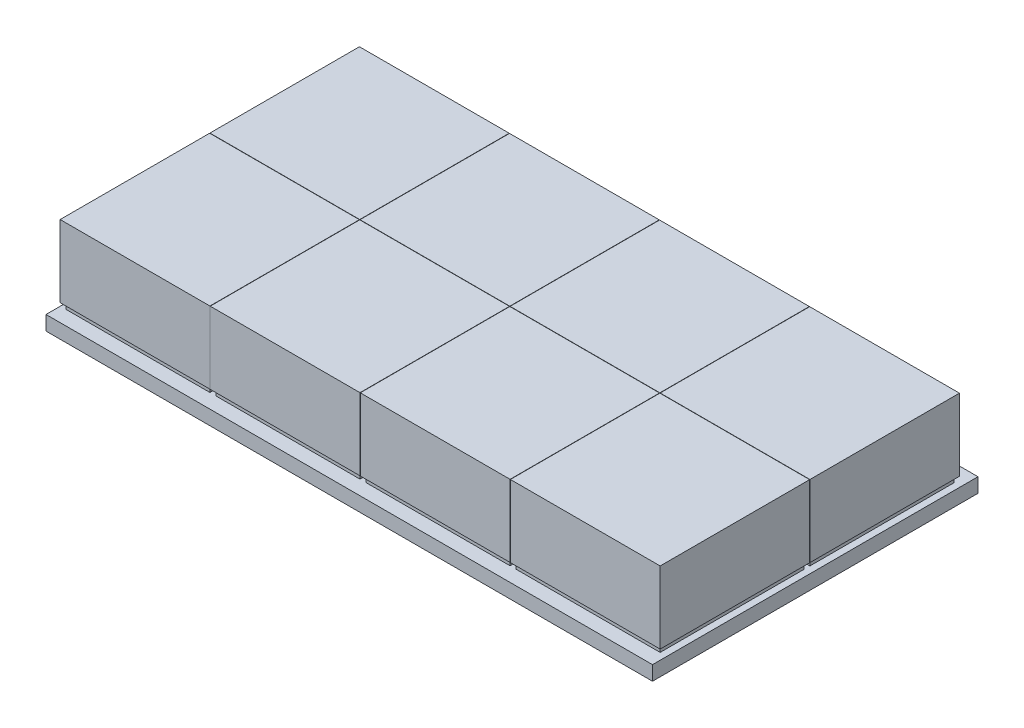
from build123d import *

# Parameters (mm, degrees)
SKETCH1_W                 = 500
SKETCH1_H                 = 113
BOSS_EXTRUDE1_DEPTH       = 5
SKETCH2_W                 = 50
SKETCH2_H                 = 50
BOSS_EXTRUDE3_DEPTH       = 2
LPATTERN1_COUNT           = 2
LPATTERN1_PITCH           = 52
SKETCH3_W                 = 52
SKETCH3_H                 = 51.9
BOSS_EXTRUDE8_DEPTH       = 25
LPATTERN5_COUNT           = 2
LPATTERN5_PITCH           = 52
LPATTERN6_COUNT           = 4
LPATTERN6_PITCH           = 52.1
LPATTERN6_COPY_1_SKETCH_W = 50
LPATTERN6_COPY_1_SKETCH_H = 50
LPATTERN6_COPY_1_DEPTH    = 2
LPATTERN6_COPY_2_SKETCH_W = 50
LPATTERN6_COPY_2_SKETCH_H = 50
LPATTERN6_COPY_2_DEPTH    = 2
LPATTERN6_COPY_3_SKETCH_W = 50
LPATTERN6_COPY_3_SKETCH_H = 50
LPATTERN6_COPY_3_DEPTH    = 2
LPATTERN6_COPY_4_SKETCH_W = 52
LPATTERN6_COPY_4_SKETCH_H = 51.9
LPATTERN6_COPY_4_DEPTH    = 25
LPATTERN6_COPY_5_SKETCH_W = 52
LPATTERN6_COPY_5_SKETCH_H = 51.9
LPATTERN6_COPY_5_DEPTH    = 25
LPATTERN6_COPY_6_SKETCH_W = 52
LPATTERN6_COPY_6_SKETCH_H = 51.9
LPATTERN6_COPY_6_DEPTH    = 25
SKETCH4_W                 = 223.089941366
SKETCH4_H                 = 113
SKETCH4_W_2               = 66.355147464
CUT_EXTRUDE1_DEPTH        = 10


with BuildPart() as part:
    # Sketch1 → Boss-Extrude1 (new body)
    with BuildSketch(Plane(origin=(0, 0, 0), x_dir=(1, 0, 0), z_dir=(0, 1, 0))):
        Rectangle(SKETCH1_W, SKETCH1_H)
    extrude(amount=BOSS_EXTRUDE1_DEPTH)

    # Sketch2 → Boss-Extrude3 (add)
    with BuildSketch(Plane(origin=(0, 5, 0), x_dir=(1, 0, 0), z_dir=(0, 1, 0))):
        with Locations((0, -26.5)):
            Rectangle(SKETCH2_W, SKETCH2_H)
    boss_extrude3 = extrude(amount=BOSS_EXTRUDE3_DEPTH)

    # LPattern1: Boss-Extrude3 ×2
    with Locations(*[(0, 0, -i * LPATTERN1_PITCH) for i in range(1, LPATTERN1_COUNT)]):
        add(boss_extrude3)

    # Sketch3 → Boss-Extrude8 (add)
    with BuildSketch(Plane(origin=(0, 7, 0), x_dir=(1, 0, 0), z_dir=(0, 1, 0))):
        with Locations((0, -26.55)):
            Rectangle(SKETCH3_W, SKETCH3_H)
    boss_extrude8 = extrude(amount=BOSS_EXTRUDE8_DEPTH)

    # LPattern5: Boss-Extrude8 ×2
    with Locations(*[(0, 0, -i * LPATTERN5_PITCH) for i in range(1, LPATTERN5_COUNT)]):
        add(boss_extrude8)

    # LPattern6: Boss-Extrude3, Boss-Extrude8 ×4
    with Locations(*[(i * LPATTERN6_PITCH, 0, 0) for i in range(1, LPATTERN6_COUNT)]):
        add(boss_extrude3)
        add(boss_extrude8)

    # LPattern6 copy 1 sketch → LPattern6 copy 1 (add)
    with BuildSketch(Plane(origin=(52.1, 5, -52), x_dir=(1, 0, 0), z_dir=(0, 1, 0))):
        with Locations((0, -26.5)):
            Rectangle(LPATTERN6_COPY_1_SKETCH_W, LPATTERN6_COPY_1_SKETCH_H)
    extrude(amount=LPATTERN6_COPY_1_DEPTH)

    # LPattern6 copy 2 sketch → LPattern6 copy 2 (add)
    with BuildSketch(Plane(origin=(104.2, 5, -52), x_dir=(1, 0, 0), z_dir=(0, 1, 0))):
        with Locations((0, -26.5)):
            Rectangle(LPATTERN6_COPY_2_SKETCH_W, LPATTERN6_COPY_2_SKETCH_H)
    extrude(amount=LPATTERN6_COPY_2_DEPTH)

    # LPattern6 copy 3 sketch → LPattern6 copy 3 (add)
    with BuildSketch(Plane(origin=(156.3, 5, -52), x_dir=(1, 0, 0), z_dir=(0, 1, 0))):
        with Locations((0, -26.5)):
            Rectangle(LPATTERN6_COPY_3_SKETCH_W, LPATTERN6_COPY_3_SKETCH_H)
    extrude(amount=LPATTERN6_COPY_3_DEPTH)

    # LPattern6 copy 4 sketch → LPattern6 copy 4 (add)
    with BuildSketch(Plane(origin=(52.1, 7, -52), x_dir=(1, 0, 0), z_dir=(0, 1, 0))):
        with Locations((0, -26.55)):
            Rectangle(LPATTERN6_COPY_4_SKETCH_W, LPATTERN6_COPY_4_SKETCH_H)
    extrude(amount=LPATTERN6_COPY_4_DEPTH)

    # LPattern6 copy 5 sketch → LPattern6 copy 5 (add)
    with BuildSketch(Plane(origin=(104.2, 7, -52), x_dir=(1, 0, 0), z_dir=(0, 1, 0))):
        with Locations((0, -26.55)):
            Rectangle(LPATTERN6_COPY_5_SKETCH_W, LPATTERN6_COPY_5_SKETCH_H)
    extrude(amount=LPATTERN6_COPY_5_DEPTH)

    # LPattern6 copy 6 sketch → LPattern6 copy 6 (add)
    with BuildSketch(Plane(origin=(156.3, 7, -52), x_dir=(1, 0, 0), z_dir=(0, 1, 0))):
        with Locations((0, -26.55)):
            Rectangle(LPATTERN6_COPY_6_SKETCH_W, LPATTERN6_COPY_6_SKETCH_H)
    extrude(amount=LPATTERN6_COPY_6_DEPTH)

    # Sketch4 → Cut-Extrude1 (cut)
    with BuildSketch(Plane(origin=(0, 5, 0), x_dir=(1, 0, 0), z_dir=(0, 1, 0))):
        with Locations((-138.455029317, 0)):
            Rectangle(SKETCH4_W, SKETCH4_H)
        with Locations((216.822426268, 0)):
            Rectangle(SKETCH4_W_2, SKETCH4_H)
    extrude(amount=-CUT_EXTRUDE1_DEPTH, mode=Mode.SUBTRACT)


solid = part.part
